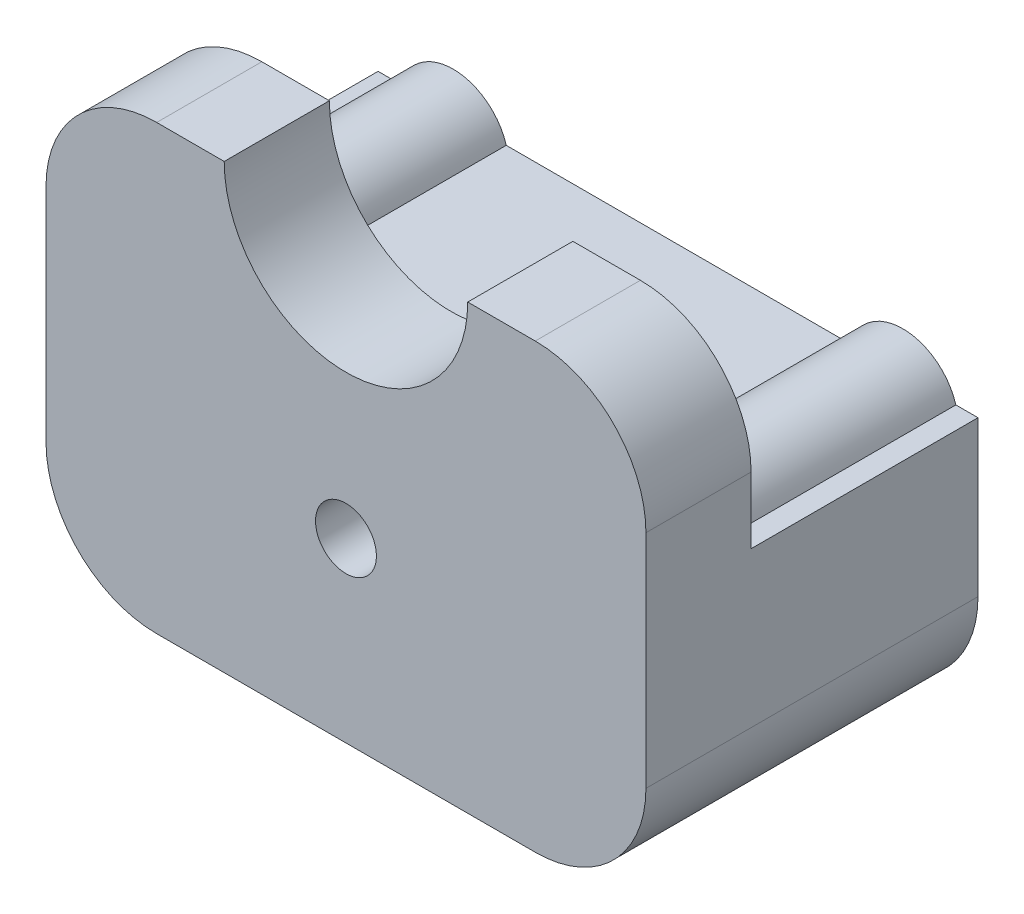
from build123d import *

# Parameters (mm, degrees)
SKETCH1_W           = 54.2
SKETCH1_H           = 25
BOSS_EXTRUDE1_DEPTH = 25
BOSS_EXTRUDE2_DEPTH = 5
FILLET1_R           = 10
FILLET2_R           = 10
CUT_EXTRUDE1_DEPTH  = 20.5
SKETCH5_R           = 2.75
CUT_EXTRUDE2_DEPTH  = 30


with BuildPart() as part:
    # Sketch1 → Boss-Extrude1 (new body)
    with BuildSketch(Plane.XY):
        with Locations((-27.1, 12.5)):
            Rectangle(SKETCH1_W, SKETCH1_H)
        Polygon((-46.2, 4), (-49.516680193, 22.809828083), (-45.577449181, 23.504420793), (-42.843601475, 8), (-11.356398525, 8), (-8.622550819, 23.504420793), (-4.683319807, 22.809828083), (-8, 4), align=None, mode=Mode.SUBTRACT)
        with BuildLine():
            Line((-54.2, 25), (0, 25))
            Line((0, 25), (0, 40))
            Line((0, 40), (-16.1, 40))
            ThreePointArc((-16.1, 40), (-27.1, 29), (-38.1, 40))
            Line((-38.1, 40), (-54.2, 40))
            Line((-54.2, 40), (-54.2, 25))
        make_face()
    extrude(amount=BOSS_EXTRUDE1_DEPTH)

    # Sketch2 → Boss-Extrude2 (add)
    with BuildSketch(Plane.XY.offset(25)):
        with BuildLine():
            Line((-54.2, 40), (-54.2, 0))
            Line((-54.2, 0), (0, 0))
            Line((0, 0), (0, 40))
            Line((0, 40), (-16.1, 40))
            ThreePointArc((-16.1, 40), (-27.1, 29), (-38.1, 40))
            Line((-38.1, 40), (-54.2, 40))
        make_face()
    extrude(amount=BOSS_EXTRUDE2_DEPTH)

    # Fillet1
    fillet1_edges = [part.edges().sort_by_distance(p)[0] for p in [
        (0, 0, 15),
        (-54.2, 0, 15),
    ]]
    fillet(fillet1_edges, radius=FILLET1_R)

    # Fillet2
    fillet2_edges = [part.edges().sort_by_distance(p)[0] for p in [
        (-54.2, 40, 15),
        (0, 40, 15),
    ]]
    fillet(fillet2_edges, radius=FILLET2_R)

    # Sketch4 → Cut-Extrude1 (cut)
    with BuildSketch(Plane(origin=(0, 0, 0), x_dir=(-1, 0, 0), z_dir=(0, 0, -1))):
        with BuildLine():
            ThreePointArc((38.1, 40), (27.1, 29), (16.1, 40))
            Line((16.1, 40), (0, 40))
            Line((0, 40), (0, 24))
            Line((0, 24), (2, 24))
            ThreePointArc((2, 24), (6.790667282, 27.568390069), (11.581334564, 24))
            Line((11.581334564, 24), (42.618665436, 24))
            ThreePointArc((42.618665436, 24), (47.409332718, 27.568390069), (52.2, 24))
            Line((52.2, 24), (54.2, 24))
            Line((54.2, 24), (54.2, 40))
            Line((54.2, 40), (38.1, 40))
        make_face()
    extrude(amount=-CUT_EXTRUDE1_DEPTH, mode=Mode.SUBTRACT)

    # Sketch5 → Cut-Extrude2 (cut)
    with BuildSketch(Plane(origin=(0, 0, 0), x_dir=(-1, 0, 0), z_dir=(0, 0, -1))):
        with Locations((27.1, 16)):
            Circle(SKETCH5_R)
    extrude(amount=-CUT_EXTRUDE2_DEPTH, mode=Mode.SUBTRACT)


solid = part.part
